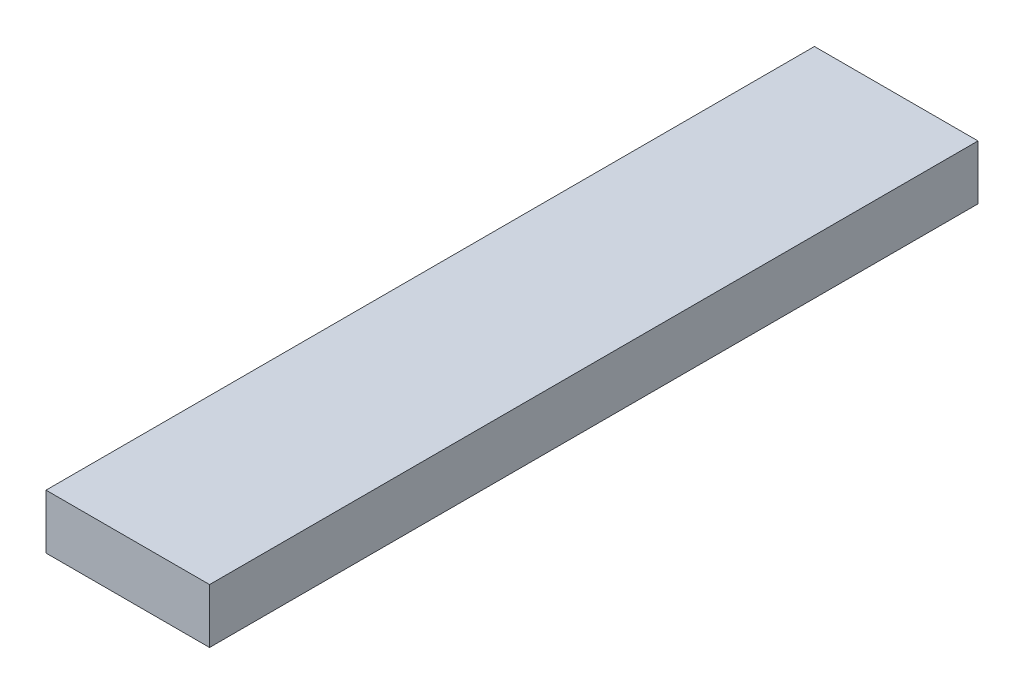
from build123d import *

# Parameters (mm, degrees)
SKETCH1_W           = 38.1
SKETCH1_H           = 12.7
BOSS_EXTRUDE1_DEPTH = 179


with BuildPart() as part:
    # Sketch1 → Boss-Extrude1 (new body)
    with BuildSketch(Plane.XY):
        with Locations((19.05, 6.35)):
            Rectangle(SKETCH1_W, SKETCH1_H)
    extrude(amount=BOSS_EXTRUDE1_DEPTH)


solid = part.part
